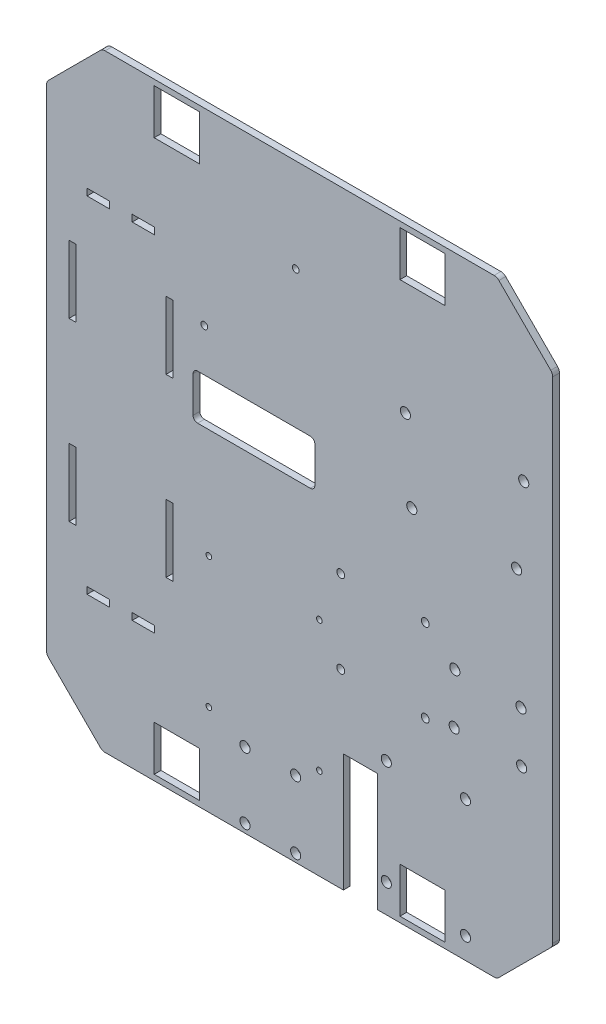
from build123d import *

# Parameters (mm, degrees)
BASE_DEPTH              = 3
ESQUISSE2_W             = 20
ESQUISSE2_H             = 20
ENL_V_MAT_EXTRU_1_DEPTH = 4
CONG_1_R                = 3
ESQUISSE4_R             = 1.25
ESQUISSE4_R_2           = 1.5
ENL_V_MAT_EXTRU_4_DEPTH = 4
ENL_V_MAT_EXTRU_5_REACH = 5
ESQUISSE5_R             = 2.25
ESQUISSE5_W             = 15.031140496
ESQUISSE5_H             = 52.322618027
PONT_H_MAL_PLACE_2_R    = 1.75
PONT_H_MAL_PLACE_DEPTH  = 3
ESQUISSE10_W            = 10
ESQUISSE10_H            = 3
ESQUISSE10_W_2          = 3
ESQUISSE10_H_2          = 30
ENL_V_MAT_EXTRU_7_DEPTH = 3


with BuildPart() as part:
    # Esquisse1 → Base (new body)
    with BuildSketch(Plane.XY):
        Polygon((0, 0), (-175, 0), (-199.748737342, 24.748737342), (-199.748737342, 244.748737342), (-175, 269.497474683), (0, 269.497474683), (24.748737342, 244.748737342), (24.748737342, 24.748737342), align=None)
    extrude(amount=BASE_DEPTH)

    # Esquisse2 → Enlèv. mat.-Extru.1 (cut, through all)
    with BuildSketch(Plane.XY.offset(3)):
        with Locations((-142, 256.997474683)):
            Rectangle(ESQUISSE2_W, ESQUISSE2_H)
        with Locations((-142, 12.5)):
            Rectangle(ESQUISSE2_W, ESQUISSE2_H)
        with Locations((-33, 12.5)):
            Rectangle(ESQUISSE2_W, ESQUISSE2_H)
        with Locations((-33, 256.997474683)):
            Rectangle(ESQUISSE2_W, ESQUISSE2_H)
    extrude(amount=-ENL_V_MAT_EXTRU_1_DEPTH, mode=Mode.SUBTRACT)

    # Congé1
    cong_1_edges = [part.edges().sort_by_distance(p)[0] for p in [
        (0, 0, 1.5),
        (-175, 0, 1.5),
        (-199.748737342, 24.748737342, 1.5),
        (-199.748737342, 244.748737342, 1.5),
        (-175, 269.497474683, 1.5),
        (0, 269.497474683, 1.5),
        (24.748737342, 244.748737342, 1.5),
        (24.748737342, 24.748737342, 1.5),
    ]]
    fillet(cong_1_edges, radius=CONG_1_R)

    # Esquisse4 → Enlèv. mat.-Extru.4 (cut, through all)
    with BuildSketch(Plane.XY.offset(3)):
        with Locations((-78.748737342, 98.497474683)):
            Circle(ESQUISSE4_R)
        with Locations((-127.748737342, 98.497474683)):
            Circle(ESQUISSE4_R)
        with Locations((-78.748737342, 40.497474683)):
            Circle(ESQUISSE4_R)
        with Locations((-127.748737342, 40.497474683)):
            Circle(ESQUISSE4_R)
        with Locations((-129.748737342, 185.997474683)):
            Circle(ESQUISSE4_R_2)
        with Locations((-89.248737342, 227.997474683)):
            Circle(ESQUISSE4_R_2)
        with BuildLine():
            Line((-82.748737342, 166.997474683), (-132.748737342, 166.997474683))
            ThreePointArc((-132.748737342, 166.997474683), (-134.162950904, 166.411688245), (-134.748737342, 164.997474683))
            Line((-134.748737342, 164.997474683), (-134.748737342, 148.997474683))
            ThreePointArc((-134.748737342, 148.997474683), (-134.162950904, 147.583261121), (-132.748737342, 146.997474683))
            Line((-132.748737342, 146.997474683), (-82.748737342, 146.997474683))
            ThreePointArc((-82.748737342, 146.997474683), (-81.334523779, 147.583261121), (-80.748737342, 148.997474683))
            Line((-80.748737342, 148.997474683), (-80.748737342, 164.997474683))
            ThreePointArc((-80.748737342, 164.997474683), (-81.334523779, 166.411688245), (-82.748737342, 166.997474683))
        make_face()
    extrude(amount=-ENL_V_MAT_EXTRU_4_DEPTH, mode=Mode.SUBTRACT)

    # Esquisse5 → Enlèv. mat.-Extru.5 (cut, up to next)
    with BuildSketch(Plane.XY.offset(3), mode=Mode.PRIVATE) as enl_v_mat_extru_5_sk1:
        with Locations((-111.738429941, 3.832493236)):
            Circle(ESQUISSE5_R)
    enl_v_mat_extru_5_tool1 = extrude(enl_v_mat_extru_5_sk1.sketch, amount=-ENL_V_MAT_EXTRU_5_REACH, mode=Mode.PRIVATE) & part.part
    add(enl_v_mat_extru_5_tool1.solids().sort_by_distance((-111.73843, 3.832493, 3))[0], mode=Mode.SUBTRACT)
    # Esquisse5 → Enlèv. mat.-Extru.5 (cut, up to next)
    with BuildSketch(Plane.XY.offset(3), mode=Mode.PRIVATE) as enl_v_mat_extru_5_sk2:
        with Locations((-89.268885084, 3.53845203)):
            Circle(ESQUISSE5_R)
    enl_v_mat_extru_5_tool2 = extrude(enl_v_mat_extru_5_sk2.sketch, amount=-ENL_V_MAT_EXTRU_5_REACH, mode=Mode.PRIVATE) & part.part
    add(enl_v_mat_extru_5_tool2.solids().sort_by_distance((-89.268885, 3.538452, 3))[0], mode=Mode.SUBTRACT)
    # Esquisse5 → Enlèv. mat.-Extru.5 (cut, up to next)
    with BuildSketch(Plane.XY.offset(3), mode=Mode.PRIVATE) as enl_v_mat_extru_5_sk3:
        with Locations((-89.268885084, 33.46154797)):
            Circle(ESQUISSE5_R)
    enl_v_mat_extru_5_tool3 = extrude(enl_v_mat_extru_5_sk3.sketch, amount=-ENL_V_MAT_EXTRU_5_REACH, mode=Mode.PRIVATE) & part.part
    add(enl_v_mat_extru_5_tool3.solids().sort_by_distance((-89.268885, 33.461548, 3))[0], mode=Mode.SUBTRACT)
    # Esquisse5 → Enlèv. mat.-Extru.5 (cut, up to next)
    with BuildSketch(Plane.XY.offset(3), mode=Mode.PRIVATE) as enl_v_mat_extru_5_sk4:
        with Locations((-111.738429941, 33.167506764)):
            Circle(ESQUISSE5_R)
    enl_v_mat_extru_5_tool4 = extrude(enl_v_mat_extru_5_sk4.sketch, amount=-ENL_V_MAT_EXTRU_5_REACH, mode=Mode.PRIVATE) & part.part
    add(enl_v_mat_extru_5_tool4.solids().sort_by_distance((-111.73843, 33.167507, 3))[0], mode=Mode.SUBTRACT)
    # Esquisse5 → Enlèv. mat.-Extru.5 (cut, up to next)
    with BuildSketch(Plane.XY.offset(3), mode=Mode.PRIVATE) as enl_v_mat_extru_5_sk5:
        with Locations((-49.05, 12.640927164)):
            Circle(ESQUISSE5_R)
    enl_v_mat_extru_5_tool5 = extrude(enl_v_mat_extru_5_sk5.sketch, amount=-ENL_V_MAT_EXTRU_5_REACH, mode=Mode.PRIVATE) & part.part
    add(enl_v_mat_extru_5_tool5.solids().sort_by_distance((-49.05, 12.640927, 3))[0], mode=Mode.SUBTRACT)
    # Esquisse5 → Enlèv. mat.-Extru.5 (cut, up to next)
    with BuildSketch(Plane.XY.offset(3), mode=Mode.PRIVATE) as enl_v_mat_extru_5_sk6:
        with Locations((-13.95, 9.5)):
            Circle(ESQUISSE5_R)
    enl_v_mat_extru_5_tool6 = extrude(enl_v_mat_extru_5_sk6.sketch, amount=-ENL_V_MAT_EXTRU_5_REACH, mode=Mode.PRIVATE) & part.part
    add(enl_v_mat_extru_5_tool6.solids().sort_by_distance((-13.95, 9.5, 3))[0], mode=Mode.SUBTRACT)
    # Esquisse5 → Enlèv. mat.-Extru.5 (cut, up to next)
    with BuildSketch(Plane.XY.offset(3), mode=Mode.PRIVATE) as enl_v_mat_extru_5_sk7:
        with Locations((-49.05, 59.140927164)):
            Circle(ESQUISSE5_R)
    enl_v_mat_extru_5_tool7 = extrude(enl_v_mat_extru_5_sk7.sketch, amount=-ENL_V_MAT_EXTRU_5_REACH, mode=Mode.PRIVATE) & part.part
    add(enl_v_mat_extru_5_tool7.solids().sort_by_distance((-49.05, 59.140927, 3))[0], mode=Mode.SUBTRACT)
    # Esquisse5 → Enlèv. mat.-Extru.5 (cut, up to next)
    with BuildSketch(Plane.XY.offset(3), mode=Mode.PRIVATE) as enl_v_mat_extru_5_sk8:
        with Locations((-13.95, 61.981854328)):
            Circle(ESQUISSE5_R)
    enl_v_mat_extru_5_tool8 = extrude(enl_v_mat_extru_5_sk8.sketch, amount=-ENL_V_MAT_EXTRU_5_REACH, mode=Mode.PRIVATE) & part.part
    add(enl_v_mat_extru_5_tool8.solids().sort_by_distance((-13.95, 61.981854, 3))[0], mode=Mode.SUBTRACT)
    # Esquisse5 → Enlèv. mat.-Extru.5 (cut, up to next)
    with BuildSketch(Plane.XY.offset(3), mode=Mode.PRIVATE) as enl_v_mat_extru_5_sk9:
        with Locations((8.748737342, 161.897474683)):
            Circle(ESQUISSE5_R)
    enl_v_mat_extru_5_tool9 = extrude(enl_v_mat_extru_5_sk9.sketch, amount=-ENL_V_MAT_EXTRU_5_REACH, mode=Mode.PRIVATE) & part.part
    add(enl_v_mat_extru_5_tool9.solids().sort_by_distance((8.748737, 161.897475, 3))[0], mode=Mode.SUBTRACT)
    # Esquisse5 → Enlèv. mat.-Extru.5 (cut, up to next)
    with BuildSketch(Plane.XY.offset(3), mode=Mode.PRIVATE) as enl_v_mat_extru_5_sk10:
        with Locations((11.889664506, 196.997474683)):
            Circle(ESQUISSE5_R)
    enl_v_mat_extru_5_tool10 = extrude(enl_v_mat_extru_5_sk10.sketch, amount=-ENL_V_MAT_EXTRU_5_REACH, mode=Mode.PRIVATE) & part.part
    add(enl_v_mat_extru_5_tool10.solids().sort_by_distance((11.889665, 196.997475, 3))[0], mode=Mode.SUBTRACT)
    # Esquisse5 → Enlèv. mat.-Extru.5 (cut, up to next)
    with BuildSketch(Plane.XY.offset(3), mode=Mode.PRIVATE) as enl_v_mat_extru_5_sk11:
        with Locations((-37.751262658, 161.897474683)):
            Circle(ESQUISSE5_R)
    enl_v_mat_extru_5_tool11 = extrude(enl_v_mat_extru_5_sk11.sketch, amount=-ENL_V_MAT_EXTRU_5_REACH, mode=Mode.PRIVATE) & part.part
    add(enl_v_mat_extru_5_tool11.solids().sort_by_distance((-37.751263, 161.897475, 3))[0], mode=Mode.SUBTRACT)
    # Esquisse5 → Enlèv. mat.-Extru.5 (cut, up to next)
    with BuildSketch(Plane.XY.offset(3), mode=Mode.PRIVATE) as enl_v_mat_extru_5_sk12:
        with Locations((-40.592189823, 196.997474683)):
            Circle(ESQUISSE5_R)
    enl_v_mat_extru_5_tool12 = extrude(enl_v_mat_extru_5_sk12.sketch, amount=-ENL_V_MAT_EXTRU_5_REACH, mode=Mode.PRIVATE) & part.part
    add(enl_v_mat_extru_5_tool12.solids().sort_by_distance((-40.59219, 196.997475, 3))[0], mode=Mode.SUBTRACT)
    # Esquisse5 → Enlèv. mat.-Extru.5 (cut, up to next)
    with BuildSketch(Plane.XY.offset(3), mode=Mode.PRIVATE) as enl_v_mat_extru_5_sk13:
        with Locations((-18.655958793, 109.451399186)):
            Circle(ESQUISSE5_R)
    enl_v_mat_extru_5_tool13 = extrude(enl_v_mat_extru_5_sk13.sketch, amount=-ENL_V_MAT_EXTRU_5_REACH, mode=Mode.PRIVATE) & part.part
    add(enl_v_mat_extru_5_tool13.solids().sort_by_distance((-18.655959, 109.451399, 3))[0], mode=Mode.SUBTRACT)
    # Esquisse5 → Enlèv. mat.-Extru.5 (cut, up to next)
    with BuildSketch(Plane.XY.offset(3), mode=Mode.PRIVATE) as enl_v_mat_extru_5_sk14:
        with Locations((-18.95, 86.981854328)):
            Circle(ESQUISSE5_R)
    enl_v_mat_extru_5_tool14 = extrude(enl_v_mat_extru_5_sk14.sketch, amount=-ENL_V_MAT_EXTRU_5_REACH, mode=Mode.PRIVATE) & part.part
    add(enl_v_mat_extru_5_tool14.solids().sort_by_distance((-18.95, 86.981854, 3))[0], mode=Mode.SUBTRACT)
    # Esquisse5 → Enlèv. mat.-Extru.5 (cut, up to next)
    with BuildSketch(Plane.XY.offset(3), mode=Mode.PRIVATE) as enl_v_mat_extru_5_sk15:
        with Locations((10.973095941, 86.981854328)):
            Circle(ESQUISSE5_R)
    enl_v_mat_extru_5_tool15 = extrude(enl_v_mat_extru_5_sk15.sketch, amount=-ENL_V_MAT_EXTRU_5_REACH, mode=Mode.PRIVATE) & part.part
    add(enl_v_mat_extru_5_tool15.solids().sort_by_distance((10.973096, 86.981854, 3))[0], mode=Mode.SUBTRACT)
    # Esquisse5 → Enlèv. mat.-Extru.5 (cut, up to next)
    with BuildSketch(Plane.XY.offset(3), mode=Mode.PRIVATE) as enl_v_mat_extru_5_sk16:
        with Locations((10.679054734, 109.451399186)):
            Circle(ESQUISSE5_R)
    enl_v_mat_extru_5_tool16 = extrude(enl_v_mat_extru_5_sk16.sketch, amount=-ENL_V_MAT_EXTRU_5_REACH, mode=Mode.PRIVATE) & part.part
    add(enl_v_mat_extru_5_tool16.solids().sort_by_distance((10.679055, 109.451399, 3))[0], mode=Mode.SUBTRACT)
    # Esquisse5 → Enlèv. mat.-Extru.5 (cut, up to next)
    with BuildSketch(Plane.XY.offset(3), mode=Mode.PRIVATE) as enl_v_mat_extru_5_sk17:
        with Locations((-60.577832016, 26.161309014)):
            Rectangle(ESQUISSE5_W, ESQUISSE5_H)
    enl_v_mat_extru_5_tool17 = extrude(enl_v_mat_extru_5_sk17.sketch, amount=-ENL_V_MAT_EXTRU_5_REACH, mode=Mode.PRIVATE) & part.part
    add(enl_v_mat_extru_5_tool17.solids().sort_by_distance((-60.577832, 26.161309, 3))[0], mode=Mode.SUBTRACT)

    # PONT H mal place 2 → pont_H_mal_place (cut)
    with BuildSketch(Plane.XY.offset(3)):
        with Locations((-69.262539319, 120.947398703)):
            Circle(PONT_H_MAL_PLACE_2_R)
        with Locations((-69.262539319, 84.205598383)):
            Circle(PONT_H_MAL_PLACE_2_R)
        with Locations((-31.776164099, 84.205598383)):
            Circle(PONT_H_MAL_PLACE_2_R)
        with Locations((-31.776164099, 120.947398703)):
            Circle(PONT_H_MAL_PLACE_2_R)
    extrude(amount=-PONT_H_MAL_PLACE_DEPTH, mode=Mode.SUBTRACT)

    # Esquisse10 → Enlèv. mat.-Extru.7 (cut)
    with BuildSketch(Plane.XY.offset(3)):
        with Locations((-176.748737342, 58.248737342)):
            Rectangle(ESQUISSE10_W, ESQUISSE10_H)
        with Locations((-188.248737342, 95.748737342)):
            Rectangle(ESQUISSE10_W_2, ESQUISSE10_H_2)
        with Locations((-156.748737342, 58.248737342)):
            Rectangle(ESQUISSE10_W, ESQUISSE10_H)
        with Locations((-145.248737342, 95.748737342)):
            Rectangle(ESQUISSE10_W_2, ESQUISSE10_H_2)
        with Locations((-188.248737342, 173.748737342)):
            Rectangle(ESQUISSE10_W_2, ESQUISSE10_H_2)
        with Locations((-156.748737342, 211.248737342)):
            Rectangle(ESQUISSE10_W, ESQUISSE10_H)
        with Locations((-176.748737342, 211.248737342)):
            Rectangle(ESQUISSE10_W, ESQUISSE10_H)
        with Locations((-145.248737342, 173.748737342)):
            Rectangle(ESQUISSE10_W_2, ESQUISSE10_H_2)
    extrude(amount=-ENL_V_MAT_EXTRU_7_DEPTH, mode=Mode.SUBTRACT)


solid = part.part
